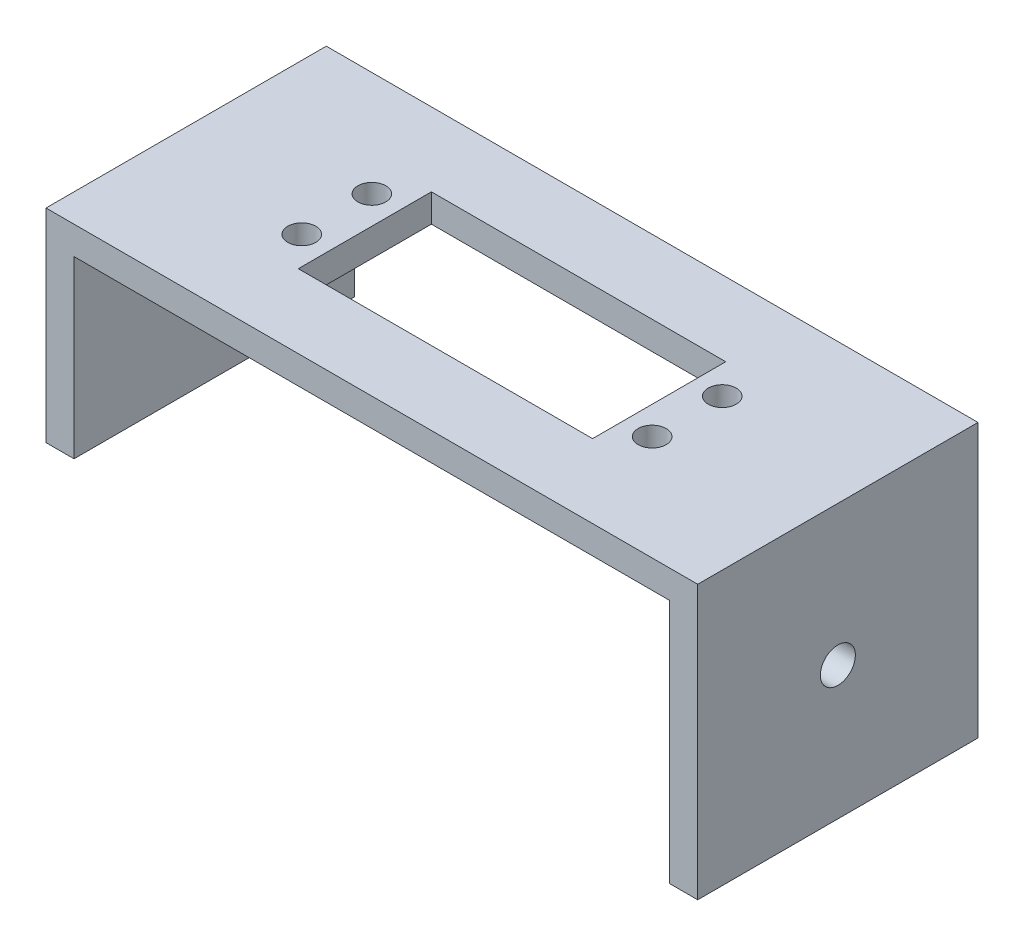
from build123d import *

# Parameters (mm, degrees)
SALIENTE_EXTRUIR1_DEPTH = 40
CROQUIS3_R              = 2.5
CORTAR_EXTRUIR1_DEPTH   = 94
CROQUIS5_W              = 40
CROQUIS5_H              = 10
CORTAR_EXTRUIR2_DEPTH   = 40
CROQUIS6_W              = 42
CROQUIS6_H              = 19
CORTAR_EXTRUIR3_DEPTH   = 10
CROQUIS7_R              = 2
CORTAR_EXTRUIR4_DEPTH   = 10


with BuildPart() as part:
    # Croquis2 → Saliente-Extruir1 (new body)
    with BuildSketch(Plane.XY):
        Polygon((-31.145916957, -11.001243781), (-31.145916957, 23.998756219), (53.854083043, 23.998756219), (53.854083043, -11.001243781), (57.854083043, -11.001243781), (57.854083043, 27.998756219), (-35.145916957, 27.998756219), (-35.145916957, -11.001243781), align=None)
    extrude(amount=SALIENTE_EXTRUIR1_DEPTH)

    # Croquis3 → Cortar-Extruir1 (cut, through all)
    with BuildSketch(Plane.ZY.offset(35.145916957)):
        with Locations((20, 7.998756219)):
            Circle(CROQUIS3_R)
    extrude(amount=-CORTAR_EXTRUIR1_DEPTH, mode=Mode.SUBTRACT)

    # Croquis5 → Cortar-Extruir2 (cut)
    with BuildSketch(Plane.ZY.offset(35.145916957)):
        with Locations((20, -6.001243781)):
            Rectangle(CROQUIS5_W, CROQUIS5_H)
    extrude(amount=-CORTAR_EXTRUIR2_DEPTH, mode=Mode.SUBTRACT)

    # Croquis6 → Cortar-Extruir3 (cut)
    with BuildSketch(Plane(origin=(0, 27.998756219, 0), x_dir=(1, 0, 0), z_dir=(0, 1, 0))):
        with Locations((11.354083043, -20)):
            Rectangle(CROQUIS6_W, CROQUIS6_H)
    extrude(amount=-CORTAR_EXTRUIR3_DEPTH, mode=Mode.SUBTRACT)

    # Croquis7 → Cortar-Extruir4 (cut)
    with BuildSketch(Plane(origin=(0, 27.998756219, 0), x_dir=(1, 0, 0), z_dir=(0, 1, 0))):
        with Locations((-13.645916957, -15)):
            Circle(CROQUIS7_R)
        with Locations((-13.645916957, -25)):
            Circle(CROQUIS7_R)
        with Locations((36.354083043, -15)):
            Circle(CROQUIS7_R)
        with Locations((36.354083043, -25)):
            Circle(CROQUIS7_R)
    extrude(amount=-CORTAR_EXTRUIR4_DEPTH, mode=Mode.SUBTRACT)


solid = part.part
